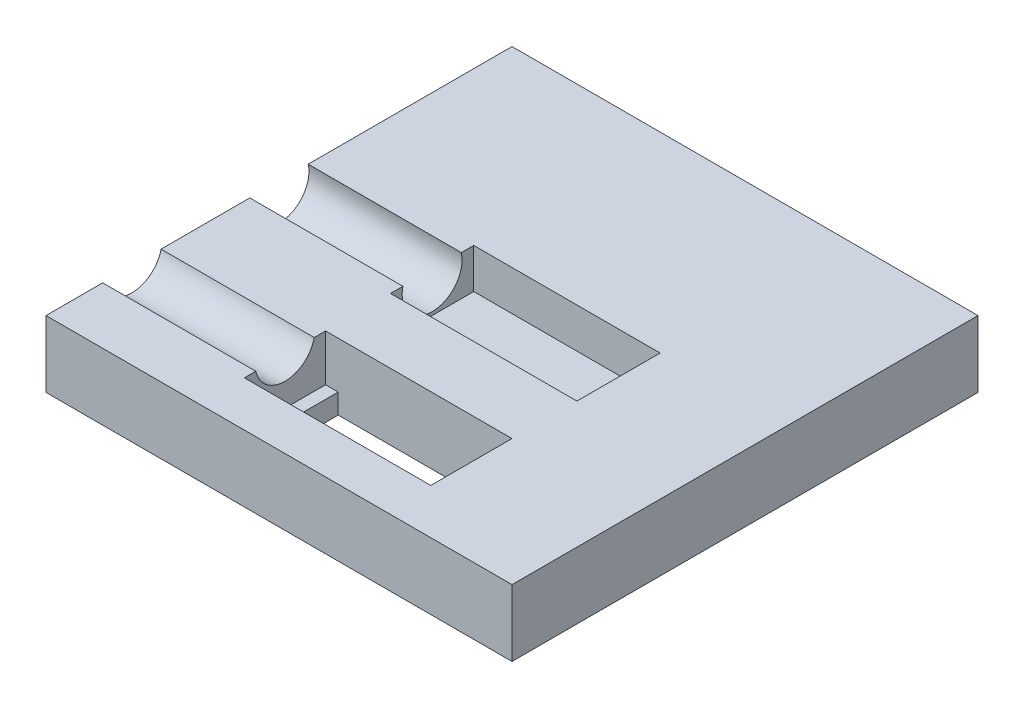
from build123d import *

# Parameters (mm, degrees)
CROQUIS1_W              = 64
CROQUIS1_H              = 64
SALIENTE_EXTRUIR1_DEPTH = 60
CROQUIS2_W              = 70
CROQUIS2_H              = 70
CROQUIS2_W_2            = 64
CROQUIS2_H_2            = 64
SALIENTE_EXTRUIR2_DEPTH = 64
CORTAR_EXTRUIR1_DEPTH   = 21
CROQUIS5_R              = 1.1
CORTAR_EXTRUIR2_DEPTH   = 10
CORTAR_EXTRUIR3_REACH   = 30
CROQUIS10_R             = 4.5
CROQUIS11_W             = 70
CROQUIS11_H             = 70
CORTAR_EXTRUIR4_DEPTH   = 30
CROQUIS12_W             = 23
CROQUIS12_H             = 12.2
CORTAR_EXTRUIR5_DEPTH   = 21
CORTAR_EXTRUIR6_REACH   = 30
CROQUIS13_R             = 4.5
CROQUIS14_R             = 1.1
CORTAR_EXTRUIR7_DEPTH   = 10
CROQUIS15_R             = 3.7
CORTAR_EXTRUIR8_DEPTH   = 10
CROQUIS16_W             = 64
CROQUIS16_H             = 64
CORTAR_EXTRUIR9_DEPTH   = 5
CROQUIS17_W             = 12.5
CROQUIS17_H             = 12.998685397
CORTAR_EXTRUIR10_DEPTH  = 5
CORTAR_EXTRUIR11_REACH  = 72
CROQUIS18_W             = 70
CROQUIS18_H             = 9
CROQUIS18_H_2           = 5.000169364
CORTAR_EXTRUIR13_DEPTH  = 5
CORTAR_EXTRUIR14_REACH  = 12
CROQUIS21_W             = 81.467019472
CROQUIS21_H             = 81.467019472
CORTAR_EXTRUIR15_REACH  = 5
CROQUIS22_W             = 3.1
CROQUIS22_H             = 12.2


with BuildPart() as part:
    # Croquis1 → Saliente-Extruir1 (new body)
    with BuildSketch(Plane(origin=(0, 0, 0), x_dir=(1, 0, 0), z_dir=(0, 1, 0))):
        Rectangle(CROQUIS1_W, CROQUIS1_H)
    extrude(amount=SALIENTE_EXTRUIR1_DEPTH)

    # Croquis2 → Saliente-Extruir2 (add)
    with BuildSketch(Plane(origin=(0, 0, 0), x_dir=(1, 0, 0), z_dir=(0, 1, 0))):
        Rectangle(CROQUIS2_W, CROQUIS2_H)
        Rectangle(CROQUIS2_W_2, CROQUIS2_H_2, mode=Mode.SUBTRACT)
    extrude(amount=SALIENTE_EXTRUIR2_DEPTH)

    # Croquis4 → Cortar-Extruir1 (cut)
    with BuildSketch(Plane(origin=(0, 60, 0), x_dir=(1, 0, 0), z_dir=(0, 1, 0))):
        Polygon((-7, 6), (-7, -6), (-7, -6.25), (16, -6.25), (16, -6), (16, 6), (16, 6.25), (-7, 6.25), align=None)
    extrude(amount=-CORTAR_EXTRUIR1_DEPTH, mode=Mode.SUBTRACT)

    # Croquis5 → Cortar-Extruir2 (cut)
    with BuildSketch(Plane(origin=(0, 60, 0), x_dir=(1, 0, 0), z_dir=(0, 1, 0))):
        with Locations((19, 0)):
            Circle(CROQUIS5_R)
        with Locations((-9, 0)):
            Circle(CROQUIS5_R)
    extrude(amount=-CORTAR_EXTRUIR2_DEPTH, mode=Mode.SUBTRACT)

    # Croquis10 → Cortar-Extruir3 (cut, up to next)
    with BuildSketch(Plane(origin=(-7, 0, 0), x_dir=(0, 0, -1), z_dir=(1, 0, 0)), mode=Mode.PRIVATE) as cortar_extruir3_sk1:
        with Locations((0, 44)):
            Circle(CROQUIS10_R)
    cortar_extruir3_tool1 = extrude(cortar_extruir3_sk1.sketch, amount=-CORTAR_EXTRUIR3_REACH, mode=Mode.PRIVATE) & part.part
    add(cortar_extruir3_tool1.solids().sort_by_distance((-7, 44, 0))[0], mode=Mode.SUBTRACT)

    # Croquis11 → Cortar-Extruir4 (cut)
    with BuildSketch(Plane.XZ):
        Rectangle(CROQUIS11_W, CROQUIS11_H)
    extrude(amount=-CORTAR_EXTRUIR4_DEPTH, mode=Mode.SUBTRACT)

    # Croquis12 → Cortar-Extruir5 (cut)
    with BuildSketch(Plane.XZ.offset(-30)):
        with Locations((4.5, 22.1)):
            Rectangle(CROQUIS12_W, CROQUIS12_H)
    extrude(amount=-CORTAR_EXTRUIR5_DEPTH, mode=Mode.SUBTRACT)

    # Croquis13 → Cortar-Extruir6 (cut, up to next)
    with BuildSketch(Plane(origin=(-7, 0, 0), x_dir=(0, 0, -1), z_dir=(1, 0, 0)), mode=Mode.PRIVATE) as cortar_extruir6_sk1:
        with Locations((-22.1, 46)):
            Circle(CROQUIS13_R)
    cortar_extruir6_tool1 = extrude(cortar_extruir6_sk1.sketch, amount=-CORTAR_EXTRUIR6_REACH, mode=Mode.PRIVATE) & part.part
    add(cortar_extruir6_tool1.solids().sort_by_distance((-7, 46, 22.1))[0], mode=Mode.SUBTRACT)

    # Croquis14 → Cortar-Extruir7 (cut)
    with BuildSketch(Plane.XZ.offset(-30)):
        with Locations((19, 22.1)):
            Circle(CROQUIS14_R)
        with Locations((-9, 22.1)):
            Circle(CROQUIS14_R)
    extrude(amount=-CORTAR_EXTRUIR7_DEPTH, mode=Mode.SUBTRACT)

    # Croquis15 → Cortar-Extruir8 (cut)
    with BuildSketch(Plane.XZ.offset(-30)):
        with Locations((0, -22.1)):
            Circle(CROQUIS15_R)
    extrude(amount=-CORTAR_EXTRUIR8_DEPTH, mode=Mode.SUBTRACT)

    # Croquis16 → Cortar-Extruir9 (cut)
    with BuildSketch(Plane(origin=(0, 60, 0), x_dir=(1, 0, 0), z_dir=(0, 1, 0))):
        Rectangle(CROQUIS16_W, CROQUIS16_H)
    extrude(amount=-CORTAR_EXTRUIR9_DEPTH, mode=Mode.SUBTRACT)

    # Croquis17 → Cortar-Extruir10 (cut)
    with BuildSketch(Plane(origin=(-7, 0, 0), x_dir=(0, 0, -1), z_dir=(1, 0, 0))):
        with Locations((0, 45.499342699)):
            Rectangle(CROQUIS17_W, CROQUIS17_H)
    extrude(amount=-CORTAR_EXTRUIR10_DEPTH, mode=Mode.SUBTRACT)

    # Croquis18 → Cortar-Extruir11 (cut, up to next)
    with BuildSketch(Plane(origin=(35, 0, 0), x_dir=(0, 0, -1), z_dir=(1, 0, 0)), mode=Mode.PRIVATE) as cortar_extruir11_sk1:
        with Locations((0, 59.5)):
            Rectangle(CROQUIS18_W, CROQUIS18_H)
    cortar_extruir11_tool1 = extrude(cortar_extruir11_sk1.sketch, amount=-CORTAR_EXTRUIR11_REACH, mode=Mode.PRIVATE) & part.part
    add(cortar_extruir11_tool1.solids().sort_by_distance((35, 59.5, 0))[0], mode=Mode.SUBTRACT)
    # Croquis18 → Cortar-Extruir11 (cut, up to next)
    with BuildSketch(Plane(origin=(35, 0, 0), x_dir=(0, 0, -1), z_dir=(1, 0, 0)), mode=Mode.PRIVATE) as cortar_extruir11_sk2:
        with Locations((0, 32.500084682)):
            Rectangle(CROQUIS18_W, CROQUIS18_H_2)
    cortar_extruir11_tool2 = extrude(cortar_extruir11_sk2.sketch, amount=-CORTAR_EXTRUIR11_REACH, mode=Mode.PRIVATE) & part.part
    add(cortar_extruir11_tool2.solids().sort_by_distance((35, 32.500085, 0))[0], mode=Mode.SUBTRACT)

    # Croquis19 → Cortar-Extruir13 (cut)
    with BuildSketch(Plane(origin=(-7, 0, 0), x_dir=(0, 0, -1), z_dir=(1, 0, 0))):
        Polygon((-16, 51), (-28.2, 51), (-28.2, 38.000169364), (-22.1, 38.000169364), (-16, 38.000169364), align=None)
    extrude(amount=-CORTAR_EXTRUIR13_DEPTH, mode=Mode.SUBTRACT)

    # Croquis21 → Cortar-Extruir14 (cut, up to next)
    with BuildSketch(Plane(origin=(0, 45.000169364, 0), x_dir=(-1, 0, 0), z_dir=(0, -1, 0)), mode=Mode.PRIVATE) as cortar_extruir14_sk1:
        with Locations((0.076423095, -0.764230952)):
            Rectangle(CROQUIS21_W, CROQUIS21_H)
    cortar_extruir14_tool1 = extrude(cortar_extruir14_sk1.sketch, amount=-CORTAR_EXTRUIR14_REACH, mode=Mode.PRIVATE) & part.part
    add(cortar_extruir14_tool1.solids().sort_by_distance((-0.076423, 45.000169, 0.764231))[0], mode=Mode.SUBTRACT)

    # Croquis22 → Cortar-Extruir15 (cut, up to next)
    with BuildSketch(Plane(origin=(0, 38.000169364, 0), x_dir=(1, 0, 0), z_dir=(0, 1, 0)), mode=Mode.PRIVATE) as cortar_extruir15_sk1:
        with Locations((-8.55, -22.1)):
            Rectangle(CROQUIS22_W, CROQUIS22_H)
    cortar_extruir15_tool1 = extrude(cortar_extruir15_sk1.sketch, amount=-CORTAR_EXTRUIR15_REACH, mode=Mode.PRIVATE) & part.part
    add(cortar_extruir15_tool1.solids().sort_by_distance((-8.55, 38.000169, 22.1))[0], mode=Mode.SUBTRACT)


solid = part.part
